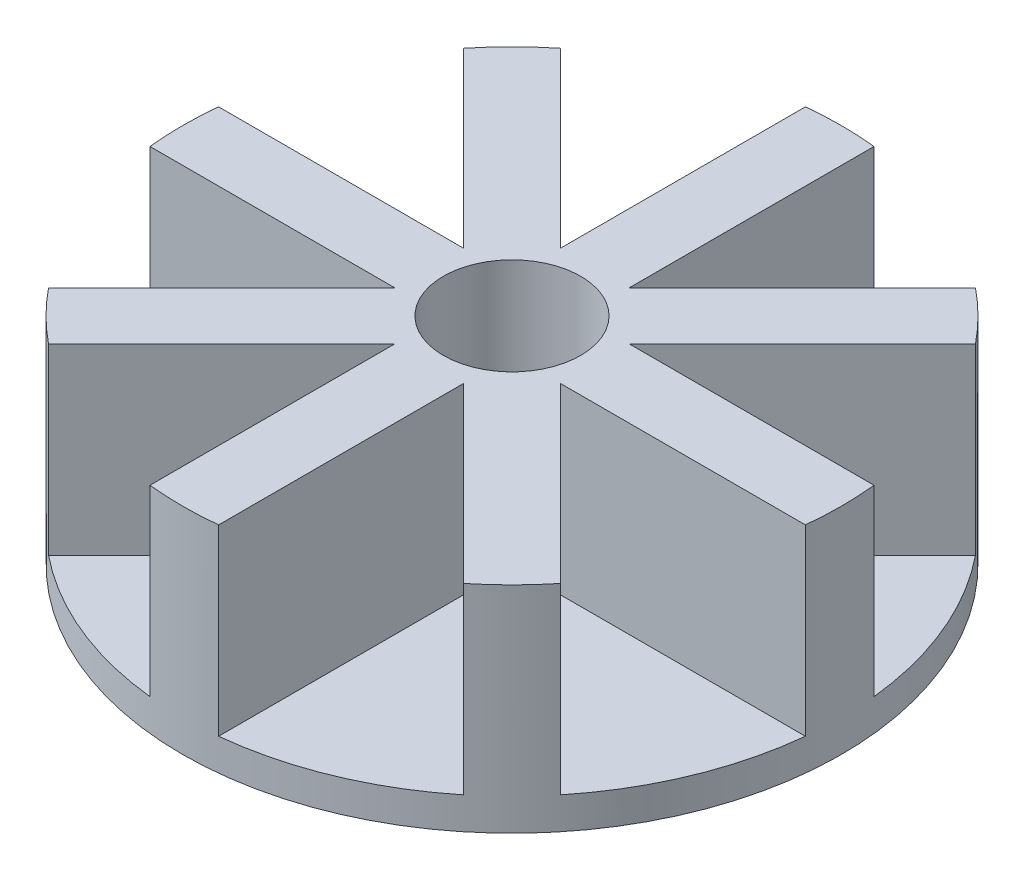
from build123d import *

# Parameters (mm, degrees)
SKETCH1_R           = 144
BOSS_EXTRUDE1_DEPTH = 94
CUT_EXTRUDE1_DEPTH  = 80
SKETCH3_R           = 4
CUT_EXTRUDE2_DEPTH  = 20
CUT_EXTRUDE3_REACH  = 96
SKETCH4_R           = 1.4
SKETCH5_R           = 30
CUT_EXTRUDE4_DEPTH  = 80


with BuildPart() as part:
    # Sketch1 → Boss-Extrude1 (new body)
    with BuildSketch(Plane(origin=(0, 0, 0), x_dir=(1, 0, 0), z_dir=(0, 1, 0))):
        Circle(SKETCH1_R)
    extrude(amount=BOSS_EXTRUDE1_DEPTH)

    # Sketch2 → Cut-Extrude1 (cut)
    with BuildSketch(Plane(origin=(0, 94, 0), x_dir=(1, 0, 0), z_dir=(0, 1, 0))):
        with BuildLine():
            Line((-15, 36.213203436), (-15, 143.216619147))
            ThreePointArc((-15, 143.216619147), (-55.106414261, 133.038652682), (-90.66284086, 111.876044296))
            Line((-90.66284086, 111.876044296), (-15, 36.213203436))
        make_face()
        with BuildLine():
            Line((15, 36.213203436), (90.66284086, 111.876044296))
            ThreePointArc((90.66284086, 111.876044296), (55.106414261, 133.038652682), (15, 143.216619147))
            Line((15, 143.216619147), (15, 36.213203436))
        make_face()
        with BuildLine():
            ThreePointArc((143.216619147, 15), (133.038652682, 55.106414261), (111.876044296, 90.66284086))
            Line((111.876044296, 90.66284086), (36.213203436, 15))
            Line((36.213203436, 15), (143.216619147, 15))
        make_face()
        with BuildLine():
            ThreePointArc((111.876044296, -90.66284086), (133.038652682, -55.106414261), (143.216619147, -15))
            Line((143.216619147, -15), (36.213203436, -15))
            Line((36.213203436, -15), (111.876044296, -90.66284086))
        make_face()
        with BuildLine():
            ThreePointArc((15, -143.216619147), (55.106414261, -133.038652682), (90.66284086, -111.876044296))
            Line((90.66284086, -111.876044296), (15, -36.213203436))
            Line((15, -36.213203436), (15, -143.216619147))
        make_face()
        with BuildLine():
            ThreePointArc((-90.66284086, -111.876044296), (-55.106414261, -133.038652682), (-15, -143.216619147))
            Line((-15, -143.216619147), (-15, -36.213203436))
            Line((-15, -36.213203436), (-90.66284086, -111.876044296))
        make_face()
        with BuildLine():
            Line((-36.213203436, -15), (-143.216619147, -15))
            ThreePointArc((-143.216619147, -15), (-133.038652682, -55.106414261), (-111.876044296, -90.66284086))
            Line((-111.876044296, -90.66284086), (-36.213203436, -15))
        make_face()
        with BuildLine():
            Line((-36.213203436, 15), (-111.876044296, 90.66284086))
            ThreePointArc((-111.876044296, 90.66284086), (-133.038652682, 55.106414261), (-143.216619147, 15))
            Line((-143.216619147, 15), (-36.213203436, 15))
        make_face()
    extrude(amount=-CUT_EXTRUDE1_DEPTH, mode=Mode.SUBTRACT)

    # Sketch3 → Cut-Extrude2 (cut)
    with BuildSketch(Plane.XZ):
        Circle(SKETCH3_R)
    extrude(amount=-CUT_EXTRUDE2_DEPTH, mode=Mode.SUBTRACT)

    # Sketch4 → Cut-Extrude3 (cut, up to next)
    with BuildSketch(Plane.XZ, mode=Mode.PRIVATE) as cut_extrude3_sk1:
        with Locations((15.5, -15.5)):
            Circle(SKETCH4_R)
    cut_extrude3_tool1 = extrude(cut_extrude3_sk1.sketch, amount=-CUT_EXTRUDE3_REACH, mode=Mode.PRIVATE) & part.part
    add(cut_extrude3_tool1.solids().sort_by_distance((15.5, 0, -15.5))[0], mode=Mode.SUBTRACT)
    # Sketch4 → Cut-Extrude3 (cut, up to next)
    with BuildSketch(Plane.XZ, mode=Mode.PRIVATE) as cut_extrude3_sk2:
        with Locations((15.5, 15.5)):
            Circle(SKETCH4_R)
    cut_extrude3_tool2 = extrude(cut_extrude3_sk2.sketch, amount=-CUT_EXTRUDE3_REACH, mode=Mode.PRIVATE) & part.part
    add(cut_extrude3_tool2.solids().sort_by_distance((15.5, 0, 15.5))[0], mode=Mode.SUBTRACT)
    # Sketch4 → Cut-Extrude3 (cut, up to next)
    with BuildSketch(Plane.XZ, mode=Mode.PRIVATE) as cut_extrude3_sk3:
        with Locations((-15.5, 15.5)):
            Circle(SKETCH4_R)
    cut_extrude3_tool3 = extrude(cut_extrude3_sk3.sketch, amount=-CUT_EXTRUDE3_REACH, mode=Mode.PRIVATE) & part.part
    add(cut_extrude3_tool3.solids().sort_by_distance((-15.5, 0, 15.5))[0], mode=Mode.SUBTRACT)
    # Sketch4 → Cut-Extrude3 (cut, up to next)
    with BuildSketch(Plane.XZ, mode=Mode.PRIVATE) as cut_extrude3_sk4:
        with Locations((-15.5, -15.5)):
            Circle(SKETCH4_R)
    cut_extrude3_tool4 = extrude(cut_extrude3_sk4.sketch, amount=-CUT_EXTRUDE3_REACH, mode=Mode.PRIVATE) & part.part
    add(cut_extrude3_tool4.solids().sort_by_distance((-15.5, 0, -15.5))[0], mode=Mode.SUBTRACT)

    # Sketch5 → Cut-Extrude4 (cut)
    with BuildSketch(Plane(origin=(0, 94, 0), x_dir=(1, 0, 0), z_dir=(0, 1, 0))):
        Circle(SKETCH5_R)
    extrude(amount=-CUT_EXTRUDE4_DEPTH, mode=Mode.SUBTRACT)


solid = part.part
